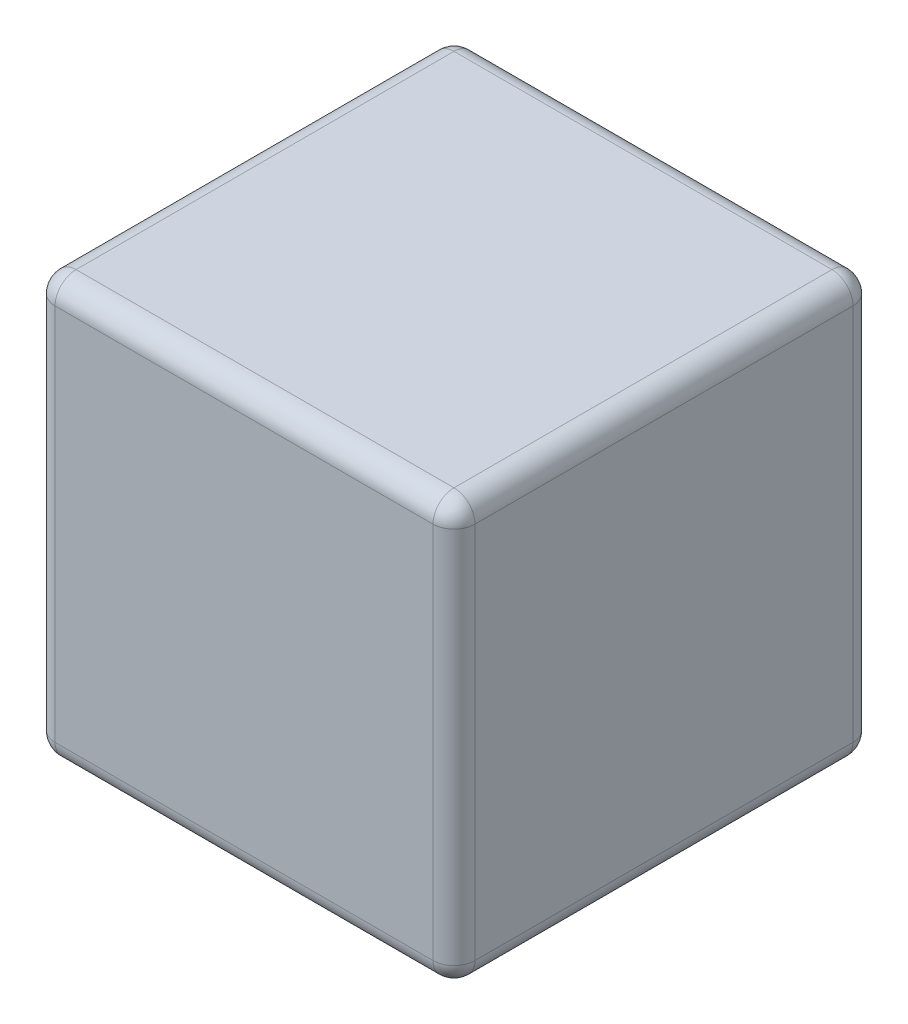
from build123d import *

# Parameters (mm, degrees)
SKETCH_1_W      = 10
SKETCH_1_H      = 10
EXTRUDE_1_DEPTH = 10
FILLET_1_R      = 0.5


with BuildPart() as part:
    # 草图1 → 凸台-拉伸1 (new body)
    with BuildSketch(Plane.XY):
        with Locations((5, 5)):
            Rectangle(SKETCH_1_W, SKETCH_1_H)
    extrude(amount=EXTRUDE_1_DEPTH)

    # 圆角1
    fillet_1_edges = [part.edges().sort_by_distance(p)[0] for p in [
        (10, 5, 10),
        (5, 10, 10),
        (0, 5, 10),
        (5, 10, 0),
        (10, 5, 0),
        (5, 0, 0),
        (0, 5, 0),
        (5, 0, 10),
        (0, 10, 5),
        (10, 10, 5),
        (10, 0, 5),
        (0, 0, 5),
    ]]
    fillet(fillet_1_edges, radius=FILLET_1_R)


solid = part.part
